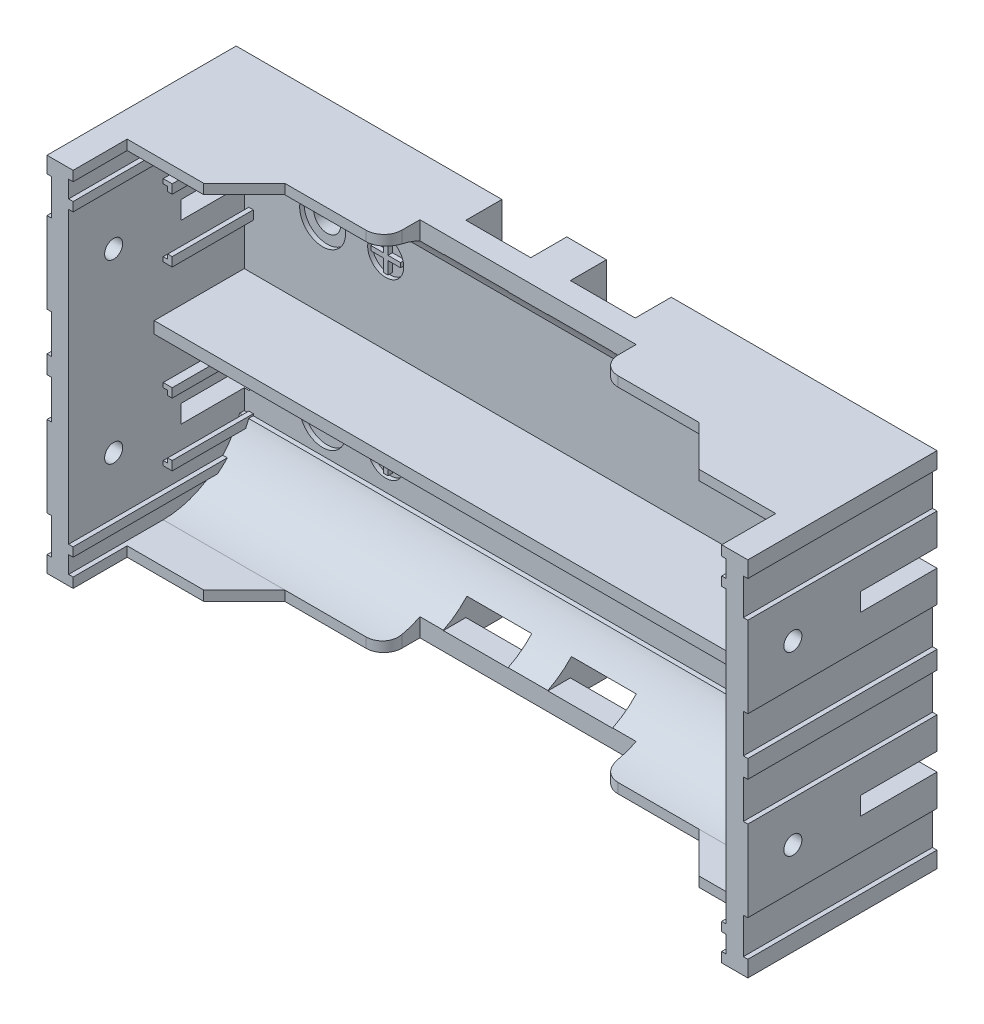
from build123d import *

# Parameters (mm, degrees)
SKETCH_1_R             = 1.6
SKETCH_1_R_2           = 1.5
EXTRUDE_450_DEPTH      = 1.5
EXTRUDE_1660_DEPTH     = 19.5
SKETCH_5_W             = 74
SKETCH_5_H             = 1.1
EXTRUDE_2071_DEPTH     = 13.5
EXTRUDE_5_DEPTH        = 74
CUT_EXTRUDE_2837_DEPTH = 45
SKETCH_3_R             = 2.55
SKETCH_3_R_2           = 2
CUT_EXTRUDE_1_DEPTH    = 0.5
EXTRUDE_3707_DEPTH     = 10
SKETCH_8_W             = 0.5
SKETCH_8_H             = 1.1
SKETCH_8_H_2           = 1
EXTRUDE_6_DEPTH        = 19.5
SKETCH_9_R             = 1
CUT_EXTRUDE_3_DEPTH    = 3
SKETCH_10_R            = 1
CUT_EXTRUDE_4_DEPTH    = 3
EXTRUDE_5920_DEPTH     = 9
SKETCH_12_W            = 7.2
SKETCH_12_H            = 4
CUT_EXTRUDE_5_DEPTH    = 4
SKETCH_13_W            = 7.2
SKETCH_13_H            = 2
CUT_EXTRUDE_6_DEPTH    = 4
SKETCH_14_R            = 2.9
SKETCH_14_R_2          = 1.5
EXTRUDE_7_DEPTH        = 0.4


with BuildPart() as part:
    # Эскиз1 → Extrude 450 (new body)
    with BuildSketch(Plane.XY):
        Polygon((-38.9, 20.1), (38.9, 20.1), (38.9, 18.3), (38.4, 18.3), (38.4, 14.3), (38.9, 14.3), (38.9, 5.3), (38.4, 5.3), (38.4, 1), (38.9, 1), (38.9, -1), (38.4, -1), (38.4, -5.3), (38.9, -5.3), (38.9, -14.3), (38.4, -14.3), (38.4, -18.3), (38.9, -18.3), (38.9, -20.1), (-38.9, -20.1), (-38.9, -18.3), (-38.4, -18.3), (-38.4, -14.3), (-38.9, -14.3), (-38.9, -5.3), (-38.4, -5.3), (-38.4, -1), (-38.9, -1), (-38.9, 1), (-38.4, 1), (-38.4, 5.3), (-38.9, 5.3), (-38.9, 14.3), (-38.4, 14.3), (-38.4, 18.3), (-38.9, 18.3), align=None)
        with Locations((27.8, 9.65)):
            Circle(SKETCH_1_R, mode=Mode.SUBTRACT)
        with Locations((-27.8, 9.65)):
            Circle(SKETCH_1_R_2, mode=Mode.SUBTRACT)
        with Locations((-27.8, -9.65)):
            Circle(SKETCH_1_R_2, mode=Mode.SUBTRACT)
        with Locations((27.8, -9.65)):
            Circle(SKETCH_1_R_2, mode=Mode.SUBTRACT)
    extrude(amount=EXTRUDE_450_DEPTH)

    # Эскиз2 → Extrude 1660 (add)
    with BuildSketch(Plane.XY.offset(1.5)):
        Polygon((38.9, 20.1), (36.5, 20.1), (36.5, -20.1), (38.9, -20.1), (38.9, -18.3), (38.4, -18.3), (38.4, -14.3), (38.9, -14.3), (38.9, -5.3), (38.4, -5.3), (38.4, -1), (38.9, -1), (38.9, 1), (38.4, 1), (38.4, 5.3), (38.9, 5.3), (38.9, 14.3), (38.4, 14.3), (38.4, 18.3), (38.9, 18.3), align=None)
        Polygon((-38.9, 20.1), (-36.5, 20.1), (-36.5, -20.1), (-38.9, -20.1), (-38.9, -18.3), (-38.4, -18.3), (-38.4, -14.3), (-38.9, -14.3), (-38.9, -5.3), (-38.4, -5.3), (-38.4, -1), (-38.9, -1), (-38.9, 1), (-38.4, 1), (-38.4, 5.3), (-38.9, 5.3), (-38.9, 14.3), (-38.4, 14.3), (-38.4, 18.3), (-38.9, 18.3), align=None)
    extrude(amount=EXTRUDE_1660_DEPTH)

    # Эскиз5 → Extrude 2071 (add)
    with BuildSketch(Plane.XY.offset(1.5)):
        with Locations((0, 19.55)):
            Rectangle(SKETCH_5_W, SKETCH_5_H)
        with Locations((0, -19.55)):
            Rectangle(SKETCH_5_W, SKETCH_5_H)
    extrude(amount=EXTRUDE_2071_DEPTH)

    # Эскиз7 → Бобышка-Вытянуть5 (add)
    with BuildSketch(Plane(origin=(-36.5, 0, 0), x_dir=(0, 0, -1), z_dir=(1, 0, 0))):
        with BuildLine():
            Line((-1.5, 19), (-10.5, 19))
            ThreePointArc((-10.5, 19), (-5.303847905, 17.348469069), (-2.014719179, 13))
            Line((-2.014719179, 13), (-1.5, 13))
            Line((-1.5, 13), (-1.5, 19))
        make_face()
        with BuildLine():
            Line((-1.5, -19), (-1.5, -13))
            Line((-1.5, -13), (-2.014718626, -13))
            ThreePointArc((-2.014718626, -13), (-5.303847577, -17.348469228), (-10.5, -19))
            Line((-10.5, -19), (-1.5, -19))
        make_face()
    extrude(amount=EXTRUDE_5_DEPTH)

    # Эскиз6 → Cut-Extrude 2837 (cut)
    with BuildSketch(Plane.XZ.offset(20.1)):
        with BuildLine():
            Line((-36.5, 15), (-27.5, 15))
            Line((-27.5, 15), (-23, 10.5))
            Line((-23, 10.5), (-14, 10.5))
            ThreePointArc((-14, 10.5), (-12.585786438, 9.914213562), (-12, 8.5))
            Line((-12, 8.5), (-12, 6.5))
            Line((-12, 6.5), (12, 6.5))
            Line((12, 6.5), (12, 8.5))
            ThreePointArc((12, 8.5), (12.585786438, 9.914213562), (14, 10.5))
            Line((14, 10.5), (23, 10.5))
            Line((23, 10.5), (27.5, 15))
            Line((27.5, 15), (36.5, 15))
            Line((36.5, 15), (36.5, 21))
            Line((36.5, 21), (-36.5, 21))
            Line((-36.5, 21), (-36.5, 15))
        make_face()
    extrude(amount=-CUT_EXTRUDE_2837_DEPTH, mode=Mode.SUBTRACT)

    # Эскиз3 → Вырез-Вытянуть1 (cut)
    with BuildSketch(Plane.XY.offset(1.5)):
        with Locations((-27.8, 9.65)):
            Circle(SKETCH_3_R)
        with Locations((27.8, 9.65)):
            Circle(SKETCH_3_R)
        with Locations((-27.8, -9.65)):
            Circle(SKETCH_3_R)
        with Locations((27.8, -9.65)):
            Circle(SKETCH_3_R)
        with Locations((-20.8, 9.65)):
            Circle(SKETCH_3_R_2)
        Polygon((-20.55, 11.3), (-20.55, 9.9), (-19.15, 9.9), (-19.15, 9.4), (-20.55, 9.4), (-20.55, 8), (-21.05, 8), (-21.05, 9.4), (-22.45, 9.4), (-22.45, 9.9), (-21.05, 9.9), (-21.05, 11.3), align=None, mode=Mode.SUBTRACT)
        with Locations((-20.8, -9.65)):
            Circle(SKETCH_3_R_2)
        Polygon((-21.05, -8), (-20.55, -8), (-20.55, -9.4), (-19.15, -9.4), (-19.15, -9.9), (-20.55, -9.9), (-20.55, -11.3), (-21.05, -11.3), (-21.05, -9.9), (-22.45, -9.9), (-22.45, -9.4), (-21.05, -9.4), align=None, mode=Mode.SUBTRACT)
        with Locations((20.8, 9.65)):
            Circle(SKETCH_3_R_2)
        Polygon((20.8, 9.9), (19.15, 9.9), (19.15, 9.4), (22.45, 9.4), (22.45, 9.9), align=None, mode=Mode.SUBTRACT)
        with Locations((20.8, -9.65)):
            Circle(SKETCH_3_R_2)
        Polygon((20.8, -9.4), (19.15, -9.4), (19.15, -9.9), (22.45, -9.9), (22.45, -9.4), align=None, mode=Mode.SUBTRACT)
    extrude(amount=-CUT_EXTRUDE_1_DEPTH, mode=Mode.SUBTRACT)

    # Эскиз4 → Extrude 3707 (add)
    with BuildSketch(Plane.XY.offset(1.5)):
        Polygon((-37, 0), (-37, 0.65), (37, 0.65), (37, -0.65), (-37, -0.65), align=None)
    extrude(amount=EXTRUDE_3707_DEPTH)

    # Эскиз8 → Бобышка-Вытянуть6 (add)
    with BuildSketch(Plane.XY.offset(1.5)):
        with Locations((-36.25, 19.55)):
            Rectangle(SKETCH_8_W, SKETCH_8_H)
        with Locations((-36.25, -19.55)):
            Rectangle(SKETCH_8_W, SKETCH_8_H)
        with Locations((-36.25, 16.6)):
            Rectangle(SKETCH_8_W, SKETCH_8_H_2)
        with Locations((36.25, -19.55)):
            Rectangle(SKETCH_8_W, SKETCH_8_H)
        with Locations((-36.25, -16.6)):
            Rectangle(SKETCH_8_W, SKETCH_8_H_2)
        with Locations((36.25, -16.6)):
            Rectangle(SKETCH_8_W, SKETCH_8_H_2)
        with Locations((36.25, 19.55)):
            Rectangle(SKETCH_8_W, SKETCH_8_H)
        with Locations((36.25, 16.6)):
            Rectangle(SKETCH_8_W, SKETCH_8_H_2)
    extrude(amount=EXTRUDE_6_DEPTH)

    # Эскиз9 → Вырез-Вытянуть3 (cut)
    with BuildSketch(Plane(origin=(38.9, 0, 0), x_dir=(0, 0, -1), z_dir=(1, 0, 0))):
        with Locations((-16, 9.8)):
            Circle(SKETCH_9_R)
        with Locations((-16, -9.8)):
            Circle(SKETCH_9_R)
        Polygon((0, 9.8), (0, 10.8), (-8.5, 10.8), (-8.5, 8.8), (0, 8.8), align=None)
        Polygon((0, -9.8), (0, -8.8), (-8.5, -8.8), (-8.5, -10.8), (0, -10.8), align=None)
    extrude(amount=-CUT_EXTRUDE_3_DEPTH, mode=Mode.SUBTRACT)

    # Эскиз10 → Вырез-Вытянуть4 (cut)
    with BuildSketch(Plane.ZY.offset(38.9)):
        with Locations((16, 9.8)):
            Circle(SKETCH_10_R)
        with Locations((16, -9.8)):
            Circle(SKETCH_10_R)
        Polygon((0, 9.8), (0, 10.8), (8.5, 10.8), (8.5, 8.8), (0, 8.8), align=None)
        Polygon((0, -9.8), (0, -8.8), (8.5, -8.8), (8.5, -10.8), (0, -10.8), align=None)
    extrude(amount=-CUT_EXTRUDE_4_DEPTH, mode=Mode.SUBTRACT)

    # Эскиз11 → Extrude 5920 (add)
    with BuildSketch(Plane.XY.offset(1.5)):
        Polygon((-36, 12.8), (-35.5, 12.8), (-35.5, 13.8), (-36.5, 13.8), (-36.5, 13.3), (-36, 13.3), align=None)
        Polygon((-36.5, 6.3), (-36, 6.3), (-36, 6.8), (-35.5, 6.8), (-35.5, 5.8), (-36.5, 5.8), align=None)
        Polygon((-36.5, -6.3), (-36, -6.3), (-36, -6.8), (-35.5, -6.8), (-35.5, -5.8), (-36.5, -5.8), align=None)
        Polygon((-36.5, -13.3), (-36, -13.3), (-36, -12.8), (-35.5, -12.8), (-35.5, -13.8), (-36.5, -13.8), align=None)
        Polygon((35.5, 13.8), (35.5, 12.8), (36, 12.8), (36, 13.3), (36.5, 13.3), (36.5, 13.8), align=None)
        Polygon((36.5, 5.8), (35.5, 5.8), (35.5, 6.8), (36, 6.8), (36, 6.3), (36.5, 6.3), align=None)
        Polygon((35.5, -5.8), (36.5, -5.8), (36.5, -6.3), (36, -6.3), (36, -6.8), (35.5, -6.8), align=None)
        Polygon((36.5, -13.3), (36.5, -13.8), (35.5, -13.8), (35.5, -12.8), (36, -12.8), (36, -13.3), align=None)
    extrude(amount=EXTRUDE_5920_DEPTH)

    # Эскиз12 → Вырез-Вытянуть5 (cut)
    with BuildSketch(Plane(origin=(0, 0, 0), x_dir=(-1, 0, 0), z_dir=(0, 0, -1))):
        with Locations((-5.8, 18.1)):
            Rectangle(SKETCH_12_W, SKETCH_12_H)
        with Locations((5.8, 18.1)):
            Rectangle(SKETCH_12_W, SKETCH_12_H)
        with Locations((-5.8, -18.1)):
            Rectangle(SKETCH_12_W, SKETCH_12_H)
        with Locations((5.8, -18.1)):
            Rectangle(SKETCH_12_W, SKETCH_12_H)
    extrude(amount=-CUT_EXTRUDE_5_DEPTH, mode=Mode.SUBTRACT)

    # Эскиз13 → Вырез-Вытянуть6 (cut)
    with BuildSketch(Plane(origin=(0, 0, 4), x_dir=(-1, 0, 0), z_dir=(0, 0, -1))):
        with Locations((-5.8, 17.1)):
            Rectangle(SKETCH_13_W, SKETCH_13_H)
        with Locations((5.8, 17.1)):
            Rectangle(SKETCH_13_W, SKETCH_13_H)
        with Locations((-5.8, -17.1)):
            Rectangle(SKETCH_13_W, SKETCH_13_H)
        with Locations((5.8, -17.1)):
            Rectangle(SKETCH_13_W, SKETCH_13_H)
    extrude(amount=-CUT_EXTRUDE_6_DEPTH, mode=Mode.SUBTRACT)

    # Эскиз14 → Бобышка-Вытянуть7 (add)
    with BuildSketch(Plane(origin=(0, 0, 0), x_dir=(-1, 0, 0), z_dir=(0, 0, -1))):
        with Locations((-27.8, 9.65)):
            Circle(SKETCH_14_R)
        with Locations((-27.8, 9.65)):
            Circle(SKETCH_14_R_2, mode=Mode.SUBTRACT)
        with Locations((-27.8, -9.65)):
            Circle(SKETCH_14_R)
        with Locations((-27.8, -9.65)):
            Circle(SKETCH_14_R_2, mode=Mode.SUBTRACT)
        with Locations((27.8, 9.65)):
            Circle(SKETCH_14_R)
        with Locations((27.8, 9.65)):
            Circle(SKETCH_14_R_2, mode=Mode.SUBTRACT)
        with Locations((27.8, -9.65)):
            Circle(SKETCH_14_R)
        with Locations((27.8, -9.65)):
            Circle(SKETCH_14_R_2, mode=Mode.SUBTRACT)
    extrude(amount=EXTRUDE_7_DEPTH)


solid = part.part
